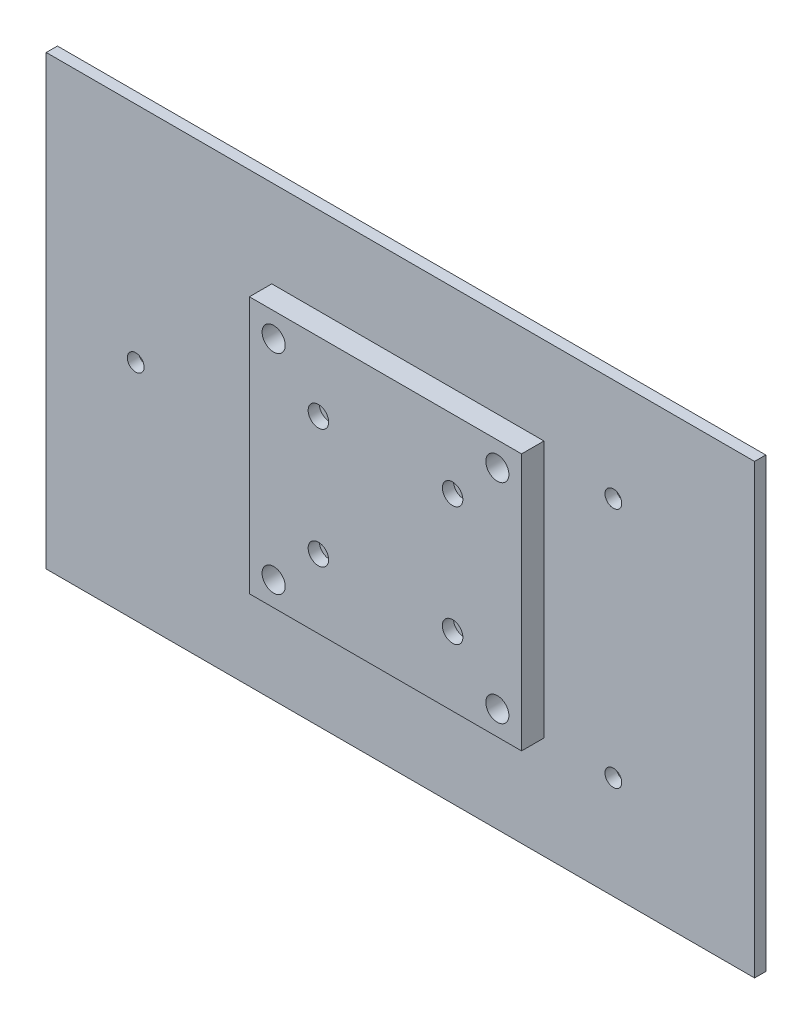
from build123d import *

# Parameters (mm, degrees)
CROQUIS1_W              = 73
CROQUIS1_H              = 69
CROQUIS1_R              = 3.1
CROQUIS1_R_2            = 1.25
SALIENTE_EXTRUIR1_DEPTH = 6
CROQUIS3_W              = 190
CROQUIS3_H              = 120
CROQUIS3_R              = 2.25
CROQUIS3_R_2            = 5
CROQUIS3_R_3            = 1.25
SALIENTE_EXTRUIR2_DEPTH = 3
CROQUIS5_R              = 2.75
CORTAR_EXTRUIR1_DEPTH   = 3


with BuildPart() as part:
    # Croquis1 → Saliente-Extruir1 (new body)
    with BuildSketch(Plane.XY):
        with Locations((36.5, 34.5)):
            Rectangle(CROQUIS1_W, CROQUIS1_H)
        with Locations((6.5, 6.5)):
            Circle(CROQUIS1_R, mode=Mode.SUBTRACT)
        with Locations((66.5, 6.5)):
            Circle(CROQUIS1_R, mode=Mode.SUBTRACT)
        with Locations((66.5, 62.5)):
            Circle(CROQUIS1_R, mode=Mode.SUBTRACT)
        with Locations((6.5, 62.5)):
            Circle(CROQUIS1_R, mode=Mode.SUBTRACT)
        with Locations((18.5, 50.5)):
            Circle(CROQUIS1_R_2, mode=Mode.SUBTRACT)
        with Locations((54.5, 50.5)):
            Circle(CROQUIS1_R_2, mode=Mode.SUBTRACT)
        with Locations((54.5, 18.5)):
            Circle(CROQUIS1_R_2, mode=Mode.SUBTRACT)
        with Locations((18.5, 18.5)):
            Circle(CROQUIS1_R_2, mode=Mode.SUBTRACT)
    extrude(amount=SALIENTE_EXTRUIR1_DEPTH)

    # Croquis3 → Saliente-Extruir2 (add)
    with BuildSketch(Plane(origin=(0, 0, 0), x_dir=(-1, 0, 0), z_dir=(0, 0, -1))):
        with Locations((-34.5, 32.5)):
            Rectangle(CROQUIS3_W, CROQUIS3_H)
        with Locations((36.5, 32.5)):
            Circle(CROQUIS3_R, mode=Mode.SUBTRACT)
        with Locations((-91.623199077, 0.069259856)):
            Circle(CROQUIS3_R, mode=Mode.SUBTRACT)
        with Locations((-91.623199077, 64.930740144)):
            Circle(CROQUIS3_R, mode=Mode.SUBTRACT)
        with Locations((-66.5, 62.5)):
            Circle(CROQUIS3_R_2, mode=Mode.SUBTRACT)
        with Locations((-6.5, 62.5)):
            Circle(CROQUIS3_R_2, mode=Mode.SUBTRACT)
        with Locations((-6.5, 6.5)):
            Circle(CROQUIS3_R_2, mode=Mode.SUBTRACT)
        with Locations((-66.5, 6.5)):
            Circle(CROQUIS3_R_2, mode=Mode.SUBTRACT)
        with Locations((-54.5, 50.5)):
            Circle(CROQUIS3_R_3, mode=Mode.SUBTRACT)
        with Locations((-18.5, 50.5)):
            Circle(CROQUIS3_R_3, mode=Mode.SUBTRACT)
        with Locations((-18.5, 18.5)):
            Circle(CROQUIS3_R_3, mode=Mode.SUBTRACT)
        with Locations((-54.5, 18.5)):
            Circle(CROQUIS3_R_3, mode=Mode.SUBTRACT)
    extrude(amount=SALIENTE_EXTRUIR2_DEPTH)

    # Croquis5 → Cortar-Extruir1 (cut)
    with BuildSketch(Plane.XY.offset(6)):
        with Locations((18.5, 50.5)):
            Circle(CROQUIS5_R)
        with Locations((54.5, 50.5)):
            Circle(CROQUIS5_R)
        with Locations((54.5, 18.5)):
            Circle(CROQUIS5_R)
        with Locations((18.5, 18.5)):
            Circle(CROQUIS5_R)
    extrude(amount=-CORTAR_EXTRUIR1_DEPTH, mode=Mode.SUBTRACT)


solid = part.part
